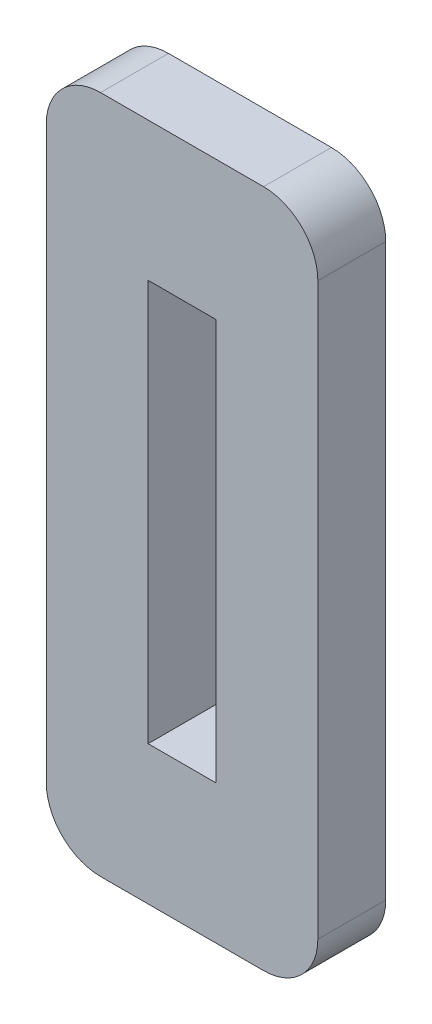
from build123d import *

# Parameters (mm, degrees)
CROQUIS1_W              = 10
CROQUIS1_H              = 25
CROQUIS1_W_2            = 2.5
CROQUIS1_H_2            = 14.7771813
SALIENTE_EXTRUIR1_DEPTH = 2.5
REDONDEO1_R             = 2


with BuildPart() as part:
    # Croquis1 → Saliente-Extruir1 (new body)
    with BuildSketch(Plane.XY):
        Rectangle(CROQUIS1_W, CROQUIS1_H)
        Rectangle(CROQUIS1_W_2, CROQUIS1_H_2, mode=Mode.SUBTRACT)
    extrude(amount=SALIENTE_EXTRUIR1_DEPTH)

    # Redondeo1
    redondeo1_edges = [part.edges().sort_by_distance(p)[0] for p in [
        (5, -12.5, 1.25),
        (-5, -12.5, 1.25),
        (-5, 12.5, 1.25),
        (5, 12.5, 1.25),
    ]]
    fillet(redondeo1_edges, radius=REDONDEO1_R)


solid = part.part
